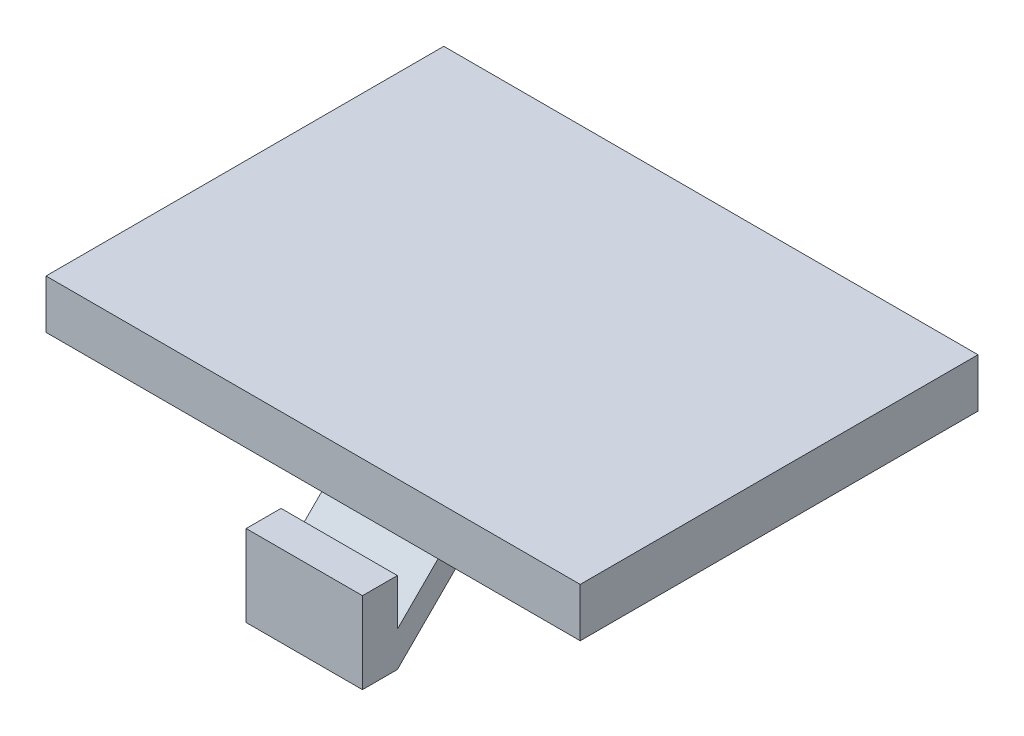
from build123d import *

# Parameters (mm, degrees)
CROQUIS1_W                   = 184
CROQUIS1_H                   = 39
SALIENTE_EXTRUIR1_DEPTH      = 17.1
CROQUIS3_W                   = 179.8
CROQUIS3_H                   = 34.8
CORTAR_EXTRUIR2_DEPTH        = 5
CROQUIS2_R                   = 0.8
CROQUIS2_W                   = 48
CROQUIS2_H                   = 1.8
CROQUIS2_W_2                 = 35
CROQUIS2_H_2                 = 5.5
CORTAR_EXTRUIR1_DEPTH        = 10
SALIENTE_EXTRUIR2_START      = -30
CROQUIS4_R                   = 1.7
SALIENTE_EXTRUIR2_DEPTH      = 10
CROQUIS5_R                   = 3
CORTAR_EXTRUIR3_DEPTH        = 2
REDONDEO1_R                  = 3
SALIENTE_EXTRUIR3_START      = -92
SALIENTE_EXTRUIR3_DEPTH      = 2.5
SALIENTE_EXTRUIR3_DEPTH_BACK = 2.5
CORTAR_EXTRUIR4_DEPTH        = 10
CORTAR_EXTRUIR4_DEPTH_BACK   = 17.1


with BuildPart() as part:
    # Croquis1 → Saliente-Extruir1 (new body)
    with BuildSketch(Plane.XY):
        with Locations((-92, 19.5)):
            Rectangle(CROQUIS1_W, CROQUIS1_H)
    extrude(amount=SALIENTE_EXTRUIR1_DEPTH)

    # Croquis3 → Cortar-Extruir2 (cut)
    with BuildSketch(Plane.XY.offset(17.1)):
        with Locations((-92, 19.5)):
            Rectangle(CROQUIS3_W, CROQUIS3_H)
    extrude(amount=-CORTAR_EXTRUIR2_DEPTH, mode=Mode.SUBTRACT)

    # Croquis2 → Cortar-Extruir1 (cut)
    with BuildSketch(Plane.XY.offset(12.1)):
        with Locations((-12.681707673, 9.800192895)):
            Circle(CROQUIS2_R)
        with Locations((-6.682537242, 9.700422497)):
            Circle(CROQUIS2_R)
        with BuildLine():
            Line((-105.9, 34.7), (-105.9, 36.2))
            Line((-105.9, 36.2), (-95.9, 36.2))
            Line((-95.9, 36.2), (-95.9, 34.7))
            Line((-95.9, 34.7), (-8.9, 34.7))
            ThreePointArc((-8.9, 34.7), (-3.7, 26.2), (-8.9, 17.7))
            Line((-8.9, 17.7), (-17.9, 17.7))
            Line((-17.9, 17.7), (-17.9, 15.7))
            Line((-17.9, 15.7), (-23.9, 15.7))
            Line((-23.9, 15.7), (-23.9, 17.7))
            Line((-23.9, 17.7), (-64.109855844, 17.7))
            Line((-64.109855844, 17.7), (-64.109855844, 5.8))
            Line((-64.109855844, 5.8), (-136.109855844, 5.8))
            Line((-136.109855844, 5.8), (-136.109855844, 8.4))
            Line((-136.109855844, 8.4), (-166.109855844, 8.4))
            ThreePointArc((-166.109855844, 8.4), (-179.9, 11.3), (-166.109855844, 14.2))
            Line((-166.109855844, 14.2), (-136.109855844, 14.2))
            Line((-136.109855844, 14.2), (-136.109855844, 16.8))
            Line((-136.109855844, 16.8), (-91.9, 16.8))
            Line((-91.9, 16.8), (-91.9, 17.7))
            Line((-91.9, 17.7), (-108.9, 17.7))
            Line((-108.9, 17.7), (-108.9, 22.7))
            Line((-108.9, 22.7), (-127.377811725, 22.7))
            ThreePointArc((-127.377811725, 22.7), (-147.1, 14.7), (-166.822188275, 22.7))
            Line((-166.822188275, 22.7), (-179.9, 22.7))
            Line((-179.9, 22.7), (-179.9, 33.7))
            Line((-179.9, 33.7), (-108.9, 33.7))
            Line((-108.9, 33.7), (-108.9, 34.7))
            Line((-108.9, 34.7), (-105.9, 34.7))
        make_face()
        with Locations((-28.1, 6.7)):
            Rectangle(CROQUIS2_W, CROQUIS2_H)
        with Locations((-44.309855844, 12.65)):
            Rectangle(CROQUIS2_W_2, CROQUIS2_H_2)
    extrude(amount=-CORTAR_EXTRUIR1_DEPTH, mode=Mode.SUBTRACT)

    # Redondeo1
    redondeo1_edges = [part.edges().sort_by_distance(p)[0] for p in [
        (-2.1, 2.1, 14.6),
        (-181.9, 2.1, 14.6),
        (-181.9, 36.9, 14.6),
        (-2.1, 36.9, 14.6),
        (0, 0, 8.55),
        (-184, 0, 8.55),
        (-184, 39, 8.55),
        (0, 39, 8.55),
    ]]
    fillet(redondeo1_edges, radius=REDONDEO1_R)


with BuildPart() as body_2:
    # Croquis4 → Saliente-Extruir2 (new body)
    with BuildSketch(Plane.ZY.offset(184).offset(SALIENTE_EXTRUIR2_START)):
        with BuildLine():
            Line((17.1, 40.5), (17.1, 39))
            Line((17.1, 39), (12.1, 39))
            Line((12.1, 39), (12.1, 45.5))
            ThreePointArc((12.1, 45.5), (20.635533906, 49.035533906), (17.1, 40.5))
        make_face()
        with Locations((17.1, 45.5)):
            Circle(CROQUIS4_R, mode=Mode.SUBTRACT)
    extrude(amount=-SALIENTE_EXTRUIR2_DEPTH)

    # Croquis5 → Cortar-Extruir3 (cut)
    with BuildSketch(Plane.ZY.offset(154)):
        with Locations((17.1, 45.5)):
            Circle(CROQUIS5_R)
    extrude(amount=-CORTAR_EXTRUIR3_DEPTH, mode=Mode.SUBTRACT)


with BuildPart() as body_3:
    # Simetría1: mirrored copy
    add(body_2.part.mirror(Plane.ZY.offset(92)))


with BuildPart() as body_4:
    # Croquis6 → Saliente-Extruir3 (new body, two sides)
    with BuildSketch(Plane.ZY.offset(184).offset(SALIENTE_EXTRUIR3_START)) as saliente_extruir3_sk:
        Polygon((12.6, 0), (11.1, 0), (16.6, -5.5), (18.1, -5.5), (18.1, -2), (16.6, -2), (16.6, -4), align=None)
    extrude(amount=SALIENTE_EXTRUIR3_DEPTH)
    extrude(saliente_extruir3_sk.sketch, amount=-SALIENTE_EXTRUIR3_DEPTH_BACK)


with BuildPart() as cortar_extruir4_tool:
    # Croquis7 → Cortar-Extruir4 (new body, two sides)
    with BuildSketch(Plane.XY.offset(17.1)) as cortar_extruir4_sk:
        Polygon((-104.103810704, 2.1), (-81.140118855, 2.1), (-81.140118855, -8.804149183), (14.735599425, -8.804149183), (14.735599425, 62.484025979), (-194.207904524, 65.472415393), (-195.251591169, -7.500518981), (-104.103810704, -8.804149183), align=None)
    extrude(amount=CORTAR_EXTRUIR4_DEPTH)
    extrude(cortar_extruir4_sk.sketch, amount=-CORTAR_EXTRUIR4_DEPTH_BACK)


with BuildPart() as part_1:
    add(part.part)

    # Cortar-Extruir4: cut by cortar_extruir4_tool
    add(cortar_extruir4_tool.part, mode=Mode.SUBTRACT)


with BuildPart() as body_2_1:
    add(body_2.part)

    # Cortar-Extruir4: cut by cortar_extruir4_tool
    add(cortar_extruir4_tool.part, mode=Mode.SUBTRACT)


with BuildPart() as body_3_1:
    add(body_3.part)

    # Cortar-Extruir4: cut by cortar_extruir4_tool
    add(cortar_extruir4_tool.part, mode=Mode.SUBTRACT)


solid = Compound([body_4.part, part_1.part])
